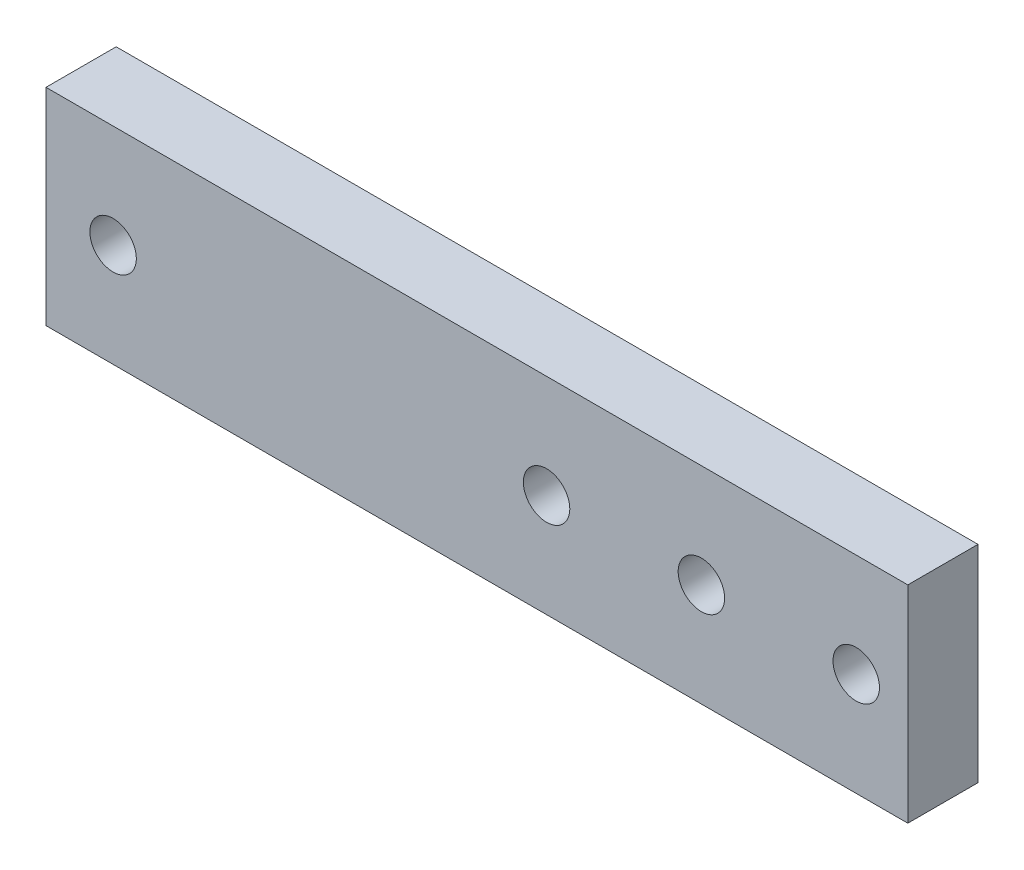
from build123d import *

# Parameters (mm, degrees)
SKETCH1_W           = 83.5
SKETCH1_H           = 20
SKETCH1_R           = 2.25
BOSS_EXTRUDE1_DEPTH = 6.8


with BuildPart() as part:
    # Sketch1 → Boss-Extrude1 (new body)
    with BuildSketch(Plane.XY):
        Rectangle(SKETCH1_W, SKETCH1_H)
        with Locations((6.75, 0)):
            Circle(SKETCH1_R, mode=Mode.SUBTRACT)
        with Locations((-35.25, 0)):
            Circle(SKETCH1_R, mode=Mode.SUBTRACT)
        with Locations((21.75, 0)):
            Circle(SKETCH1_R, mode=Mode.SUBTRACT)
        with Locations((36.75, 0)):
            Circle(SKETCH1_R, mode=Mode.SUBTRACT)
    extrude(amount=BOSS_EXTRUDE1_DEPTH)


solid = part.part
